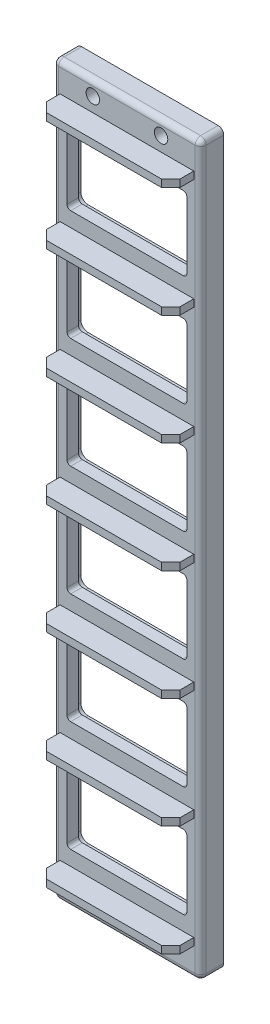
from build123d import *

# Parameters (mm, degrees)
SKETCH2_W             = 18.415
SKETCH2_H             = 1.016
BOSS_EXTRUDE1_DEPTH   = 6.35
CHAMFER1_SIZE         = 1.27
LPATTERN2_COUNT       = 7
LPATTERN2_PITCH       = 15.24
SKETCH3_W             = 20.32
SKETCH3_H             = 100.33
SKETCH3_W_2           = 16.51
SKETCH3_H_2           = 10.16
BOSS_EXTRUDE2_DEPTH   = 3.175
FILLET1_R             = 0.762
F_0_CLEARANCE_HOLE1_D = 1.8542
FILLET2_R             = 0.508
CUT_EXTRUDE1_DEPTH    = 1.5875
LPATTERN3_COUNT       = 6
LPATTERN3_PITCH       = 15.24


with BuildPart() as part:
    # Sketch2 → Boss-Extrude1 (new body)
    with BuildSketch(Plane.XY):
        with Locations((-92.71, -107.569)):
            Rectangle(SKETCH2_W, SKETCH2_H)
    extrude(amount=BOSS_EXTRUDE1_DEPTH)

    # Chamfer1
    chamfer1_edges = [part.edges().sort_by_distance(p)[0] for p in [
        (-83.5025, -107.569, 6.35),
        (-101.9175, -107.569, 6.35),
    ]]
    chamfer(chamfer1_edges, length=CHAMFER1_SIZE)


with BuildPart() as lpattern2_1:
    # LPattern2: pattern copy
    add(part.part.moved(Location(Vector(0, 1, 0) * (1 * LPATTERN2_PITCH))))


with BuildPart() as lpattern2_2:
    # LPattern2: pattern copy
    add(part.part.moved(Location(Vector(0, 1, 0) * (2 * LPATTERN2_PITCH))))


with BuildPart() as lpattern2_3:
    # LPattern2: pattern copy
    add(part.part.moved(Location(Vector(0, 1, 0) * (3 * LPATTERN2_PITCH))))


with BuildPart() as lpattern2_4:
    # LPattern2: pattern copy
    add(part.part.moved(Location(Vector(0, 1, 0) * (4 * LPATTERN2_PITCH))))


with BuildPart() as lpattern2_5:
    # LPattern2: pattern copy
    add(part.part.moved(Location(Vector(0, 1, 0) * (5 * LPATTERN2_PITCH))))


with BuildPart() as lpattern2_6:
    # LPattern2: pattern copy
    add(part.part.moved(Location(Vector(0, 1, 0) * (6 * LPATTERN2_PITCH))))


with BuildPart() as part_1:
    add(part.part)

    add(lpattern2_1.part)  # Boss-Extrude2 merges LPattern2_1

    add(lpattern2_2.part)  # Boss-Extrude2 merges LPattern2_2

    add(lpattern2_3.part)  # Boss-Extrude2 merges LPattern2_3

    add(lpattern2_4.part)  # Boss-Extrude2 merges LPattern2_4

    add(lpattern2_5.part)  # Boss-Extrude2 merges LPattern2_5

    add(lpattern2_6.part)  # Boss-Extrude2 merges LPattern2_6
    # Sketch3 → Boss-Extrude2 (add)
    with BuildSketch(Plane.XY):
        with Locations((-92.71, -61.849)):
            Rectangle(SKETCH3_W, SKETCH3_H)
        with Locations((-92.71, -99.949)):
            Rectangle(SKETCH3_W_2, SKETCH3_H_2, mode=Mode.SUBTRACT)
        with Locations((-92.71, -84.709)):
            Rectangle(SKETCH3_W_2, SKETCH3_H_2, mode=Mode.SUBTRACT)
        with Locations((-92.71, -69.469)):
            Rectangle(SKETCH3_W_2, SKETCH3_H_2, mode=Mode.SUBTRACT)
        with Locations((-92.71, -54.229)):
            Rectangle(SKETCH3_W_2, SKETCH3_H_2, mode=Mode.SUBTRACT)
        with Locations((-92.71, -38.989)):
            Rectangle(SKETCH3_W_2, SKETCH3_H_2, mode=Mode.SUBTRACT)
        with Locations((-92.71, -23.749)):
            Rectangle(SKETCH3_W_2, SKETCH3_H_2, mode=Mode.SUBTRACT)
    extrude(amount=BOSS_EXTRUDE2_DEPTH)

    # Fillet1
    fillet1_edges = [part_1.edges().sort_by_distance(p)[0] for p in [
        (-102.87, -61.849, 3.175),
        (-92.71, -112.014, 3.175),
        (-82.55, -61.849, 3.175),
        (-92.71, -11.684, 3.175),
        (-102.87, -11.684, 1.5875),
        (-102.87, -112.014, 1.5875),
        (-82.55, -112.014, 1.5875),
        (-82.55, -11.684, 1.5875),
    ]]
    fillet(fillet1_edges, radius=FILLET1_R)

    # #0 Clearance Hole1 (through all)
    with Locations(Plane.XY.offset(3.175)):
        with Locations((-97.409, -13.6525), (-88.011, -13.6525), (-97.409, -110.0455), (-88.011, -110.0455)):
            Hole(F_0_CLEARANCE_HOLE1_D / 2)

    # Fillet2
    fillet2_edges = [part_1.edges().sort_by_distance(p)[0] for p in [
        (-84.455, -94.869, 1.5875),
        (-100.965, -94.869, 1.5875),
        (-100.965, -105.029, 1.5875),
        (-84.455, -105.029, 1.5875),
        (-84.455, -89.789, 1.5875),
        (-84.455, -79.629, 1.5875),
        (-100.965, -79.629, 1.5875),
        (-100.965, -89.789, 1.5875),
        (-84.455, -74.549, 1.5875),
        (-84.455, -64.389, 1.5875),
        (-100.965, -64.389, 1.5875),
        (-100.965, -74.549, 1.5875),
        (-84.455, -59.309, 1.5875),
        (-84.455, -49.149, 1.5875),
        (-100.965, -49.149, 1.5875),
        (-100.965, -59.309, 1.5875),
        (-84.455, -44.069, 1.5875),
        (-84.455, -33.909, 1.5875),
        (-100.965, -33.909, 1.5875),
        (-100.965, -44.069, 1.5875),
        (-84.455, -28.829, 1.5875),
        (-84.455, -18.669, 1.5875),
        (-100.965, -18.669, 1.5875),
        (-100.965, -28.829, 1.5875),
    ]]
    fillet(fillet2_edges, radius=FILLET2_R)

    # Sketch9 → Cut-Extrude1 (cut)
    with BuildSketch(Plane(origin=(0, 0, 0), x_dir=(-1, 0, 0), z_dir=(0, 0, -1))):
        with BuildLine():
            Line((102.235, -105.283), (102.235, -94.615))
            ThreePointArc((102.235, -94.615), (101.93742049, -93.89657951), (101.219, -93.599))
            Line((101.219, -93.599), (84.201, -93.599))
            ThreePointArc((84.201, -93.599), (83.48257951, -93.89657951), (83.185, -94.615))
            Line((83.185, -94.615), (83.185, -105.283))
            ThreePointArc((83.185, -105.283), (83.48257951, -106.00142049), (84.201, -106.299))
            Line((84.201, -106.299), (101.219, -106.299))
            ThreePointArc((101.219, -106.299), (101.93742049, -106.00142049), (102.235, -105.283))
        make_face()
    cut_extrude1 = extrude(amount=-CUT_EXTRUDE1_DEPTH, mode=Mode.SUBTRACT)

    # LPattern3: Cut-Extrude1 ×6
    with Locations(*[(0, i * LPATTERN3_PITCH, 0) for i in range(1, LPATTERN3_COUNT)]):
        add(cut_extrude1, mode=Mode.SUBTRACT)


solid = part_1.part
